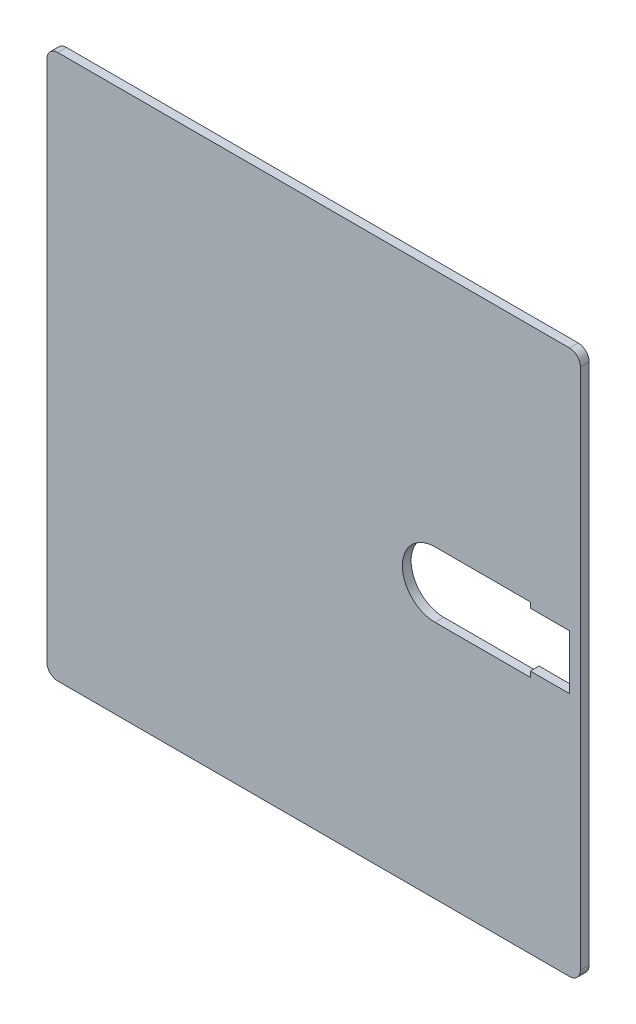
from build123d import *

# Parameters (mm, degrees)
SKETCH_1_W      = 98
SKETCH_1_H      = 100
EXTRUDE_1_DEPTH = 1.6
FILLET_1_R      = 2


with BuildPart() as part:
    # 草图1 → 凸台-拉伸1 (new body)
    with BuildSketch(Plane.XY):
        with Locations((49, 50)):
            Rectangle(SKETCH_1_W, SKETCH_1_H)
        with BuildLine():
            Line((96, 55), (96, 50))
            Line((96, 50), (96, 45))
            Line((96, 45), (88.8, 45))
            Line((88.8, 45), (88.8, 44))
            Line((88.8, 44), (71.3, 44))
            ThreePointArc((71.3, 44), (65.3, 50), (71.3, 56))
            Line((71.3, 56), (88.8, 56))
            Line((88.8, 56), (88.8, 55))
            Line((88.8, 55), (96, 55))
        make_face(mode=Mode.SUBTRACT)
    extrude(amount=EXTRUDE_1_DEPTH)

    # 圆角1
    fillet_1_edges = [part.edges().sort_by_distance(p)[0] for p in [
        (0, 0, 0.8),
        (0, 100, 0.8),
        (98, 100, 0.8),
        (98, 0, 0.8),
    ]]
    fillet(fillet_1_edges, radius=FILLET_1_R)


solid = part.part
